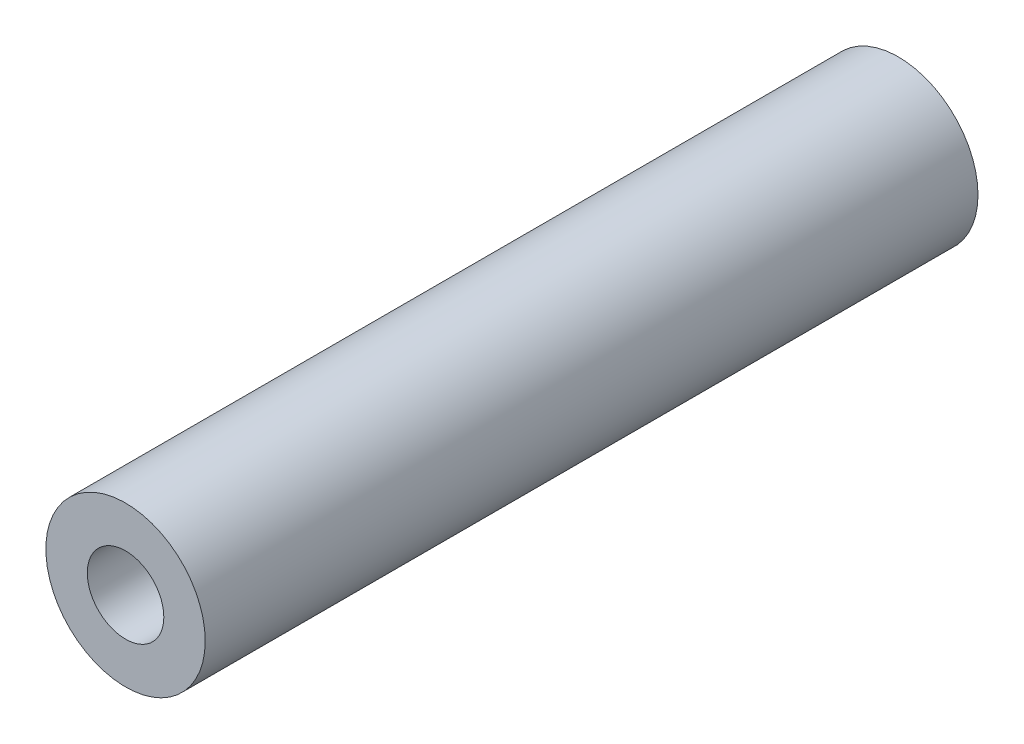
from build123d import *

# Parameters (mm, degrees)
SKETCH1_R          = 0.25781
EXTRUDE1_DEPTH     = 2.5
SKETCH2_R          = 0.123825
CUT_EXTRUDE1_DEPTH = 2.5


with BuildPart() as part:
    # Sketch1 → Extrude1 (new body)
    with BuildSketch(Plane.XY):
        with Locations((-7.72417103, 4.709860384)):
            Circle(SKETCH1_R)
    extrude(amount=EXTRUDE1_DEPTH)

    # Sketch2 → Cut-Extrude1 (cut)
    with BuildSketch(Plane.XY.offset(2.5)):
        with Locations((-7.72417103, 4.709860384)):
            Circle(SKETCH2_R)
    extrude(amount=-CUT_EXTRUDE1_DEPTH, mode=Mode.SUBTRACT)


solid = part.part
